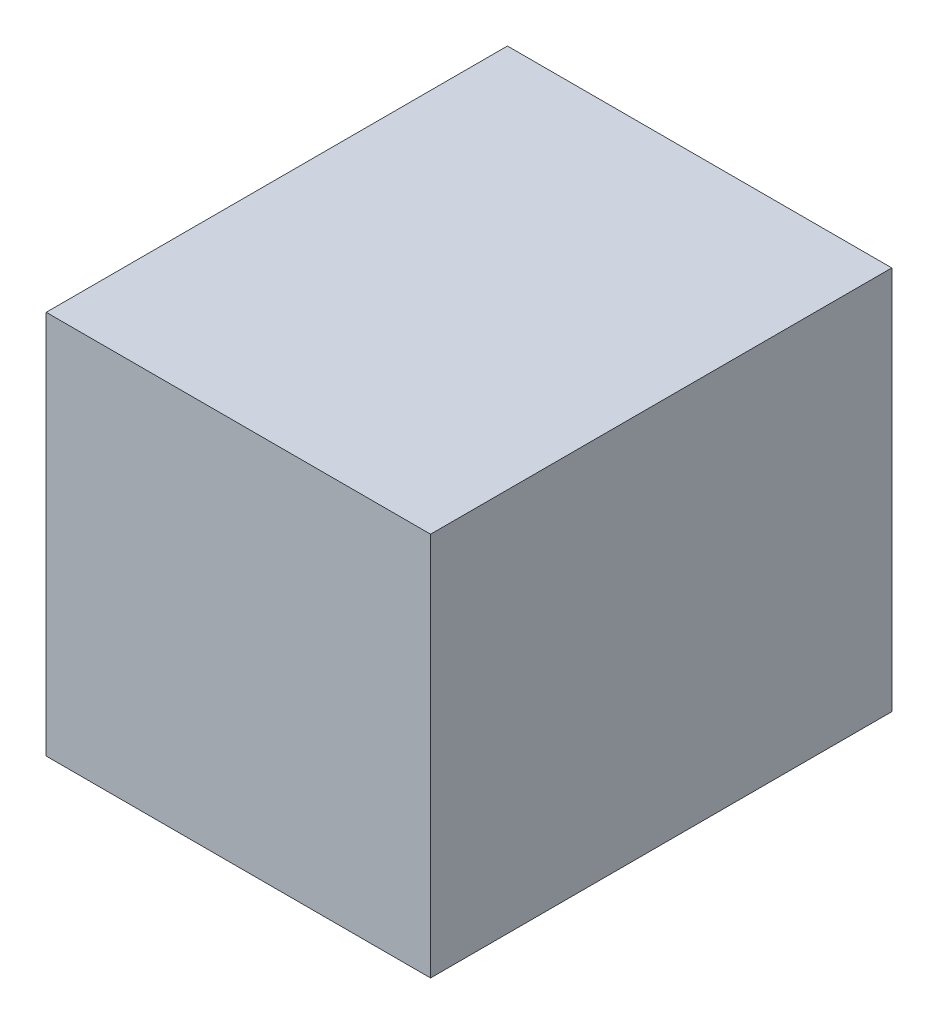
from build123d import *

# Parameters (mm, degrees)
SKETCH1_W           = 5
SKETCH1_H           = 5
BOSS_EXTRUDE1_DEPTH = 3


with BuildPart() as part:
    # Sketch1 → Boss-Extrude1 (new body, symmetric)
    with BuildSketch(Plane.XY):
        Rectangle(SKETCH1_W, SKETCH1_H)
    extrude(amount=BOSS_EXTRUDE1_DEPTH, both=True)


solid = part.part
